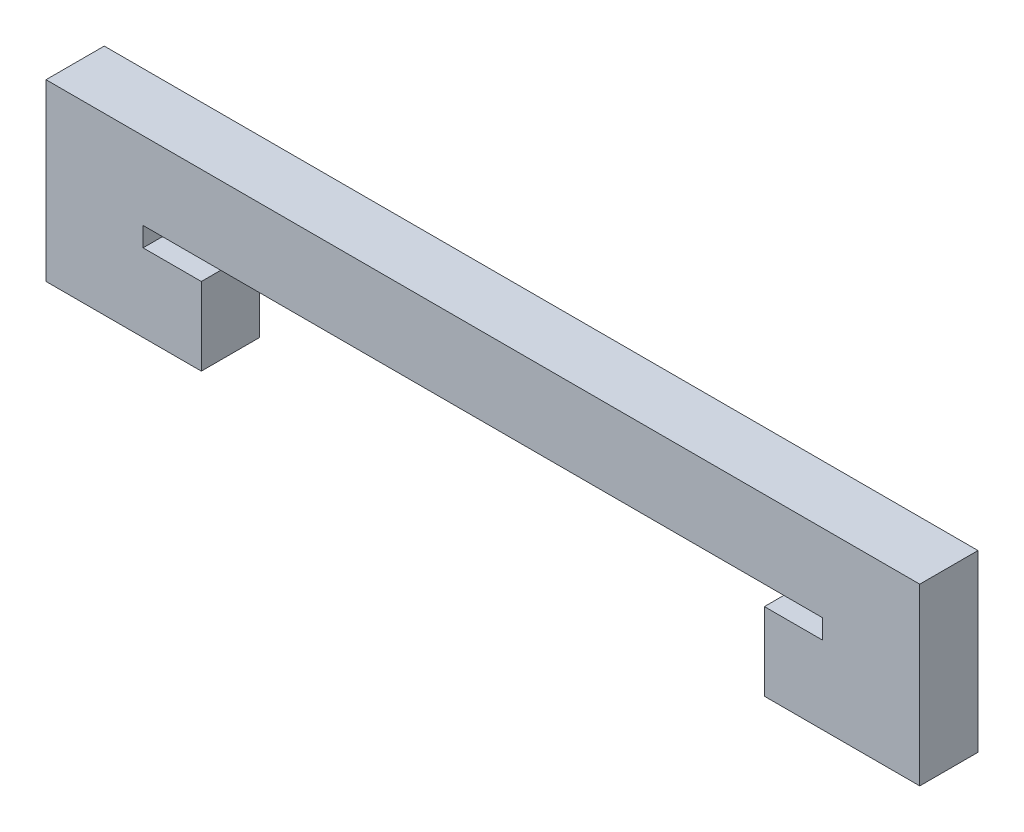
from build123d import *

# Parameters (mm, degrees)
BOSS_EXTRUDE1_DEPTH = 3


with BuildPart() as part:
    # Sketch2 → Boss-Extrude1 (new body)
    with BuildSketch(Plane.XY):
        Polygon((-17.5, 0), (-17.5, -1), (-14.5, -1), (-14.5, -5), (-22.5, -5), (-22.5, 0), (-22.5, 4), (22.5, 4), (22.5, -5), (14.5, -5), (14.5, -1), (17.5, -1), (17.5, 0), align=None)
    extrude(amount=BOSS_EXTRUDE1_DEPTH)


solid = part.part
